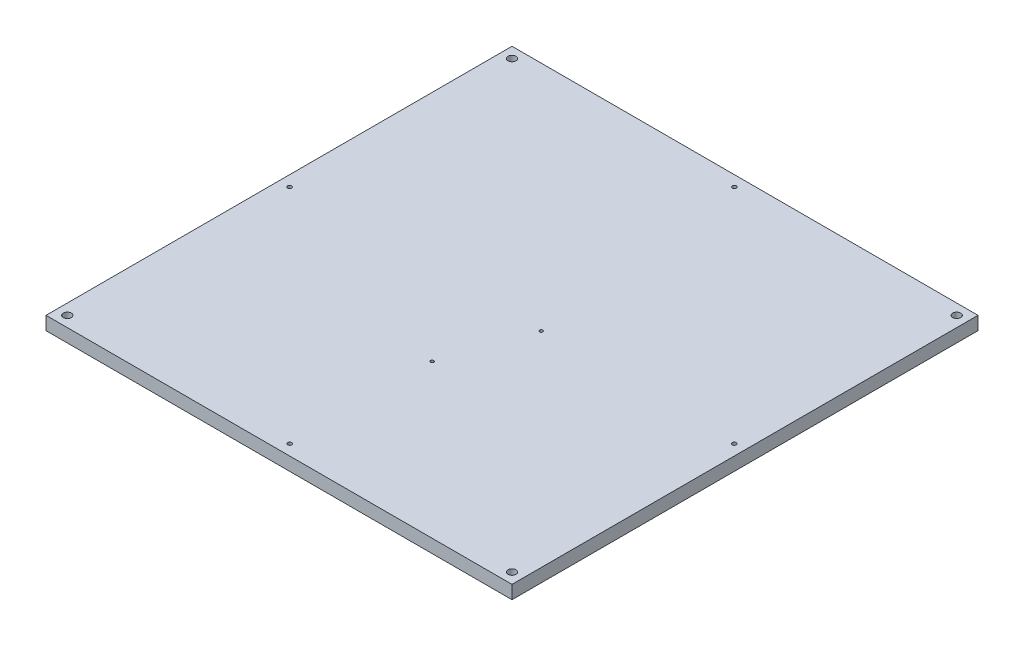
from build123d import *

# Parameters (mm, degrees)
SKETCH1_W           = 2000
SKETCH1_H           = 2000
BOSS_EXTRUDE1_DEPTH = 50
SKETCH2_R           = 6
CUT_EXTRUDE1_DEPTH  = 30
SKETCH3_W           = 2000
SKETCH3_H           = 50
CUT_EXTRUDE2_DEPTH  = 250
SKETCH4_W           = 1750
SKETCH4_H           = 50
CUT_EXTRUDE3_DEPTH  = 125
SKETCH5_W           = 1750
SKETCH5_H           = 50
CUT_EXTRUDE4_DEPTH  = 125
SKETCH6_R           = 15
SKETCH6_R_2         = 7.5
CUT_EXTRUDE5_DEPTH  = 25


with BuildPart() as part:
    # Sketch1 → Boss-Extrude1 (new body)
    with BuildSketch(Plane(origin=(0, 0, 0), x_dir=(1, 0, 0), z_dir=(0, 1, 0))):
        Rectangle(SKETCH1_W, SKETCH1_H)
    extrude(amount=-BOSS_EXTRUDE1_DEPTH)

    # Sketch2 → Cut-Extrude1 (cut)
    with BuildSketch(Plane(origin=(0, 0, 0), x_dir=(1, 0, 0), z_dir=(0, 1, 0))):
        with Locations((0, -175)):
            Circle(SKETCH2_R)
        with Locations((106, 129)):
            Circle(SKETCH2_R)
    extrude(amount=-CUT_EXTRUDE1_DEPTH, mode=Mode.SUBTRACT)

    # Sketch3 → Cut-Extrude2 (cut)
    with BuildSketch(Plane.XY.offset(1000)):
        with Locations((0, -25)):
            Rectangle(SKETCH3_W, SKETCH3_H)
    extrude(amount=-CUT_EXTRUDE2_DEPTH, mode=Mode.SUBTRACT)

    # Sketch4 → Cut-Extrude3 (cut)
    with BuildSketch(Plane.ZY.offset(1000)):
        with Locations((-125, -25)):
            Rectangle(SKETCH4_W, SKETCH4_H)
    extrude(amount=-CUT_EXTRUDE3_DEPTH, mode=Mode.SUBTRACT)

    # Sketch5 → Cut-Extrude4 (cut)
    with BuildSketch(Plane(origin=(1000, 0, 0), x_dir=(0, 0, -1), z_dir=(1, 0, 0))):
        with Locations((125, -25)):
            Rectangle(SKETCH5_W, SKETCH5_H)
    extrude(amount=-CUT_EXTRUDE4_DEPTH, mode=Mode.SUBTRACT)

    # Sketch6 → Cut-Extrude5 (cut)
    with BuildSketch(Plane(origin=(0, 0, 0), x_dir=(1, 0, 0), z_dir=(0, 1, 0))):
        with Locations((-835, -710)):
            Circle(SKETCH6_R)
        with Locations((835, 960)):
            Circle(SKETCH6_R)
        with Locations((835, -710)):
            Circle(SKETCH6_R)
        with Locations((-835, 960)):
            Circle(SKETCH6_R)
        with Locations((0, -710)):
            Circle(SKETCH6_R_2)
        with Locations((0, 960)):
            Circle(SKETCH6_R_2)
        with Locations((-835, 125)):
            Circle(SKETCH6_R_2)
        with Locations((835, 125)):
            Circle(SKETCH6_R_2)
    extrude(amount=-CUT_EXTRUDE5_DEPTH, mode=Mode.SUBTRACT)


solid = part.part
